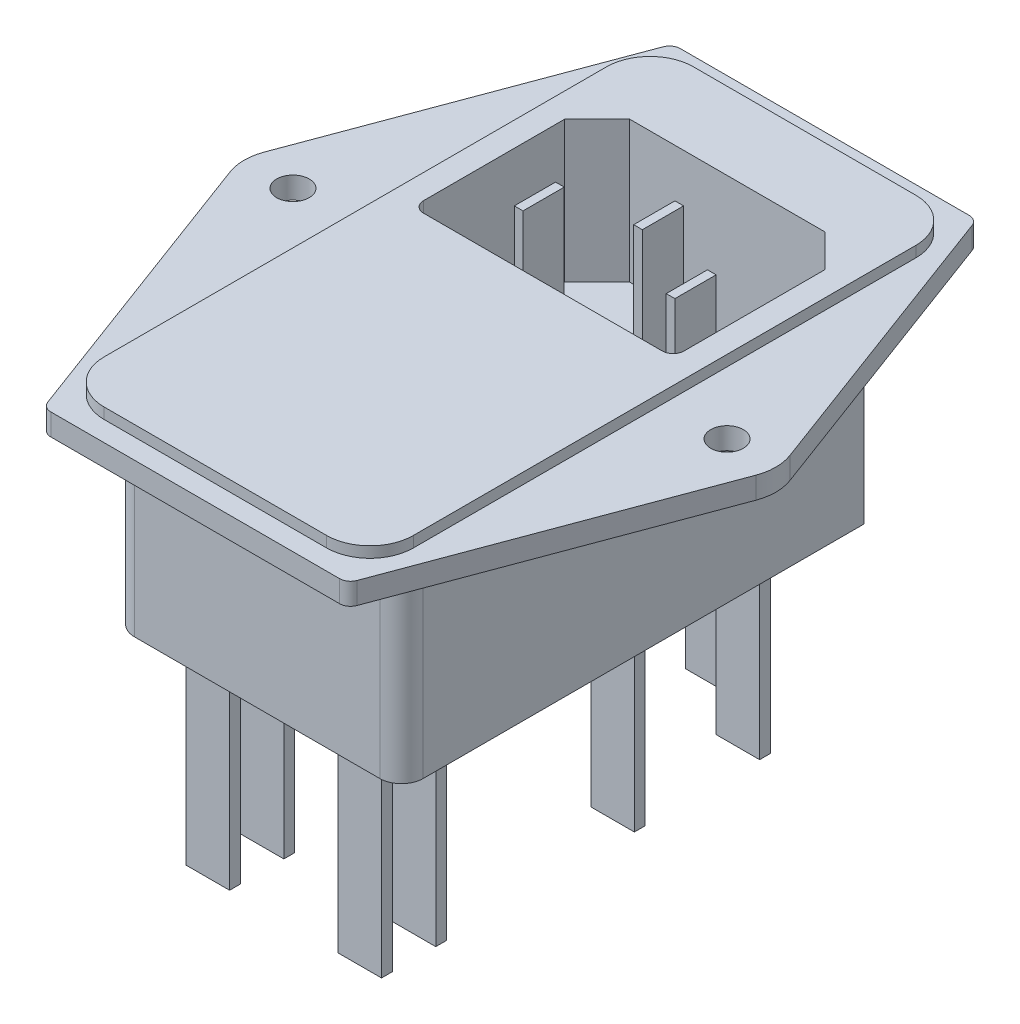
from build123d import *

# Parameters (mm, degrees)
SKETCH_1_R          = 1.5
EXTRUDE_1_DEPTH     = 2
EXTRUDE_2_DEPTH     = 17.8
EXTRUDE_3_DEPTH     = 1
CUT_EXTRUDE_START   = 1
CUT_EXTRUDE_1_DEPTH = 13
SKETCH_5_W          = 0.8
SKETCH_5_H          = 3.8
EXTRUDE_4_DEPTH     = 13
SKETCH_6_W          = 4
SKETCH_6_H          = 1
EXTRUDE_5_DEPTH     = 18


with BuildPart() as part:
    # 草图1 → 凸台-拉伸1 (new body)
    with BuildSketch(Plane(origin=(0, 0, 0), x_dir=(1, 0, 0), z_dir=(0, 1, 0))):
        with BuildLine():
            Line((-24.216959088, 1.570750156), (-14.242466434, 28.34905559))
            ThreePointArc((-14.242466434, 28.34905559), (-13.875866128, 28.821296411), (-13.305364415, 29))
            Line((-13.305364415, 29), (13.305364415, 29))
            ThreePointArc((13.305364415, 29), (13.875866128, 28.821296411), (14.242466434, 28.34905559))
            Line((14.242466434, 28.34905559), (24.216959088, 1.570750156))
            ThreePointArc((24.216959088, 1.570750156), (24.5, 0), (24.216959088, -1.570750156))
            Line((24.216959088, -1.570750156), (14.242466434, -28.34905559))
            ThreePointArc((14.242466434, -28.34905559), (13.875866128, -28.821296411), (13.305364415, -29))
            Line((13.305364415, -29), (-13.305364415, -29))
            ThreePointArc((-13.305364415, -29), (-13.875866128, -28.821296411), (-14.242466434, -28.34905559))
            Line((-14.242466434, -28.34905559), (-24.216959088, -1.570750156))
            ThreePointArc((-24.216959088, -1.570750156), (-24.5, 0), (-24.216959088, 1.570750156))
        make_face()
        with Locations((-20, 0)):
            Circle(SKETCH_1_R, mode=Mode.SUBTRACT)
        with Locations((20, 0)):
            Circle(SKETCH_1_R, mode=Mode.SUBTRACT)
    extrude(amount=EXTRUDE_1_DEPTH)

    # 草图2 → 凸台-拉伸2 (add)
    with BuildSketch(Plane.XZ):
        with BuildLine():
            Line((-13.3, -19.3), (-9.3, -23.3))
            Line((-9.3, -23.3), (9.3, -23.3))
            Line((9.3, -23.3), (13.3, -19.3))
            Line((13.3, -19.3), (13.3, 21.3))
            ThreePointArc((13.3, 21.3), (12.714213562, 22.714213562), (11.3, 23.3))
            Line((11.3, 23.3), (-11.3, 23.3))
            ThreePointArc((-11.3, 23.3), (-12.714213562, 22.714213562), (-13.3, 21.3))
            Line((-13.3, 21.3), (-13.3, -19.3))
        make_face()
    extrude(amount=EXTRUDE_2_DEPTH)

    # 草图4 → 凸台-拉伸3 (add)
    with BuildSketch(Plane(origin=(0, 2, 0), x_dir=(1, 0, 0), z_dir=(0, 1, 0))):
        with BuildLine():
            Line((-10.25, 27.15), (10.25, 27.15))
            ThreePointArc((10.25, 27.15), (13.078427125, 25.978427125), (14.25, 23.15))
            Line((14.25, 23.15), (14.25, -23.15))
            ThreePointArc((14.25, -23.15), (13.078427125, -25.978427125), (10.25, -27.15))
            Line((10.25, -27.15), (-10.25, -27.15))
            ThreePointArc((-10.25, -27.15), (-13.078427125, -25.978427125), (-14.25, -23.15))
            Line((-14.25, -23.15), (-14.25, 23.15))
            ThreePointArc((-14.25, 23.15), (-13.078427125, 25.978427125), (-10.25, 27.15))
        make_face()
    extrude(amount=EXTRUDE_3_DEPTH)

    # 草图3 → 切除-拉伸1 (cut)
    with BuildSketch(Plane(origin=(0, 2, 0), x_dir=(1, 0, 0), z_dir=(0, 1, 0)).offset(CUT_EXTRUDE_START)):
        with BuildLine():
            Line((-9, 20.034278181), (9, 20.034278181))
            Line((9, 20.034278181), (12, 17.034278181))
            Line((12, 17.034278181), (12, 4.034278181))
            ThreePointArc((12, 4.034278181), (11.707106781, 3.327171399), (11, 3.034278181))
            Line((11, 3.034278181), (-11, 3.034278181))
            ThreePointArc((-11, 3.034278181), (-11.707106781, 3.327171399), (-12, 4.034278181))
            Line((-12, 4.034278181), (-12, 17.034278181))
            Line((-12, 17.034278181), (-9, 20.034278181))
        make_face()
    extrude(amount=-CUT_EXTRUDE_1_DEPTH, mode=Mode.SUBTRACT)

    # 草图5 → 凸台-拉伸4 (add)
    with BuildSketch(Plane(origin=(0, -10, 0), x_dir=(1, 0, 0), z_dir=(0, 1, 0))):
        with Locations((-7, 9.698034266)):
            Rectangle(SKETCH_5_W, SKETCH_5_H)
        with Locations((0, 13.698034266)):
            Rectangle(SKETCH_5_W, SKETCH_5_H)
        with Locations((7, 9.698034266)):
            Rectangle(SKETCH_5_W, SKETCH_5_H)
    extrude(amount=EXTRUDE_4_DEPTH)

    # 草图6 → 凸台-拉伸5 (add)
    with BuildSketch(Plane.XZ.offset(17.8)):
        with Locations((7.3, 20.63986364)):
            Rectangle(SKETCH_6_W, SKETCH_6_H)
        with Locations((-6.7, 20.63986364)):
            Rectangle(SKETCH_6_W, SKETCH_6_H)
        with Locations((7.3, 15.63986364)):
            Rectangle(SKETCH_6_W, SKETCH_6_H)
        with Locations((-6.7, 15.63986364)):
            Rectangle(SKETCH_6_W, SKETCH_6_H)
        with Locations((7.3, -2.659527469)):
            Rectangle(SKETCH_6_W, SKETCH_6_H)
        with Locations((7.3, -14.202737865)):
            Rectangle(SKETCH_6_W, SKETCH_6_H)
        with Locations((0.634367625, -18.047402207)):
            Rectangle(SKETCH_6_W, SKETCH_6_H)
    extrude(amount=EXTRUDE_5_DEPTH)


solid = part.part
